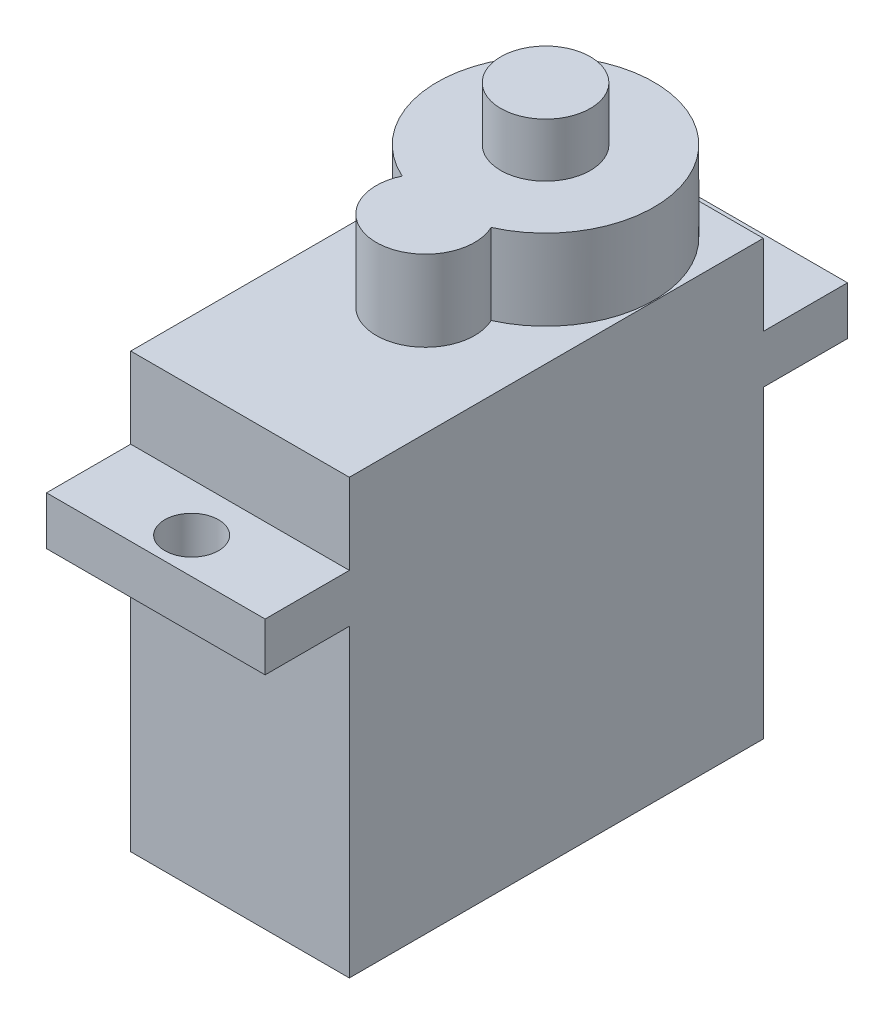
from build123d import *

# Parameters (mm, degrees)
SKETCH1_W           = 12.2
SKETCH1_H           = 23.1
BOSS_EXTRUDE3_DEPTH = 24.2
SKETCH5_W           = 12.2
SKETCH5_H           = 2.7
BOSS_EXTRUDE4_DEPTH = 4.7
CUT_EXTRUDE4_START  = -20.7
SKETCH6_R           = 1.5
CUT_EXTRUDE4_DEPTH  = 26.2
SKETCH7_R           = 2.75
SKETCH7_R_2         = 6.05
BOSS_EXTRUDE5_DEPTH = 4.5
SKETCH8_R           = 2.5
BOSS_EXTRUDE6_DEPTH = 3


with BuildPart() as part:
    # Sketch1 → Boss-Extrude3 (new body)
    with BuildSketch(Plane(origin=(0, 0, 0), x_dir=(1, 0, 0), z_dir=(0, 1, 0))):
        Rectangle(SKETCH1_W, SKETCH1_H)
    extrude(amount=BOSS_EXTRUDE3_DEPTH)

    # Sketch5 → Boss-Extrude4 (add)
    with BuildSketch(Plane.XY.offset(11.55)):
        with Locations((0, 18.35)):
            Rectangle(SKETCH5_W, SKETCH5_H)
    boss_extrude4 = extrude(amount=BOSS_EXTRUDE4_DEPTH)

    # Sketch6 → Cut-Extrude4 (cut)
    with BuildSketch(Plane(origin=(0, 19.7, 0), x_dir=(1, 0, 0), z_dir=(0, 1, 0)).offset(CUT_EXTRUDE4_START)):
        with Locations((0, -14.25)):
            Circle(SKETCH6_R)
    cut_extrude4 = extrude(amount=CUT_EXTRUDE4_DEPTH, mode=Mode.SUBTRACT)

    # Mirror3: Boss-Extrude4, Cut-Extrude4 across plane
    add(boss_extrude4.mirror(Plane.XY))
    add(cut_extrude4.mirror(Plane.XY), mode=Mode.SUBTRACT)

    # Sketch7 → Boss-Extrude5 (add)
    with BuildSketch(Plane(origin=(0, 24.2, 0), x_dir=(1, 0, 0), z_dir=(0, 1, 0))):
        with Locations((0, -1.2)):
            Circle(SKETCH7_R)
        with Locations((0, 5.5)):
            Circle(SKETCH7_R_2)
    extrude(amount=BOSS_EXTRUDE5_DEPTH)

    # Sketch8 → Boss-Extrude6 (add)
    with BuildSketch(Plane(origin=(0, 28.7, 0), x_dir=(1, 0, 0), z_dir=(0, 1, 0))):
        with Locations((0, 5.5)):
            Circle(SKETCH8_R)
    extrude(amount=BOSS_EXTRUDE6_DEPTH)


solid = part.part
